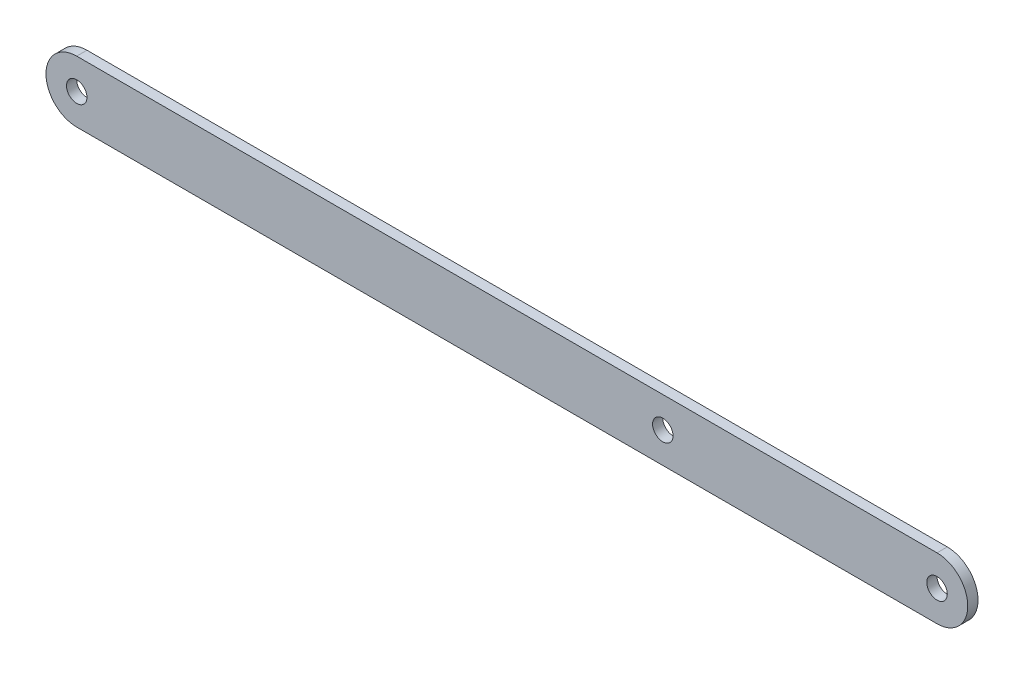
from build123d import *

# Parameters (mm, degrees)
SKETCH2_R           = 12.7
BOSS_EXTRUDE1_DEPTH = 12.7
SKETCH3_R           = 12.7
CUT_EXTRUDE1_DEPTH  = 13.7


with BuildPart() as part:
    # Sketch2 → Boss-Extrude1 (new body)
    with BuildSketch(Plane.XY):
        with BuildLine():
            Line((0, 38.1), (1066.8, 38.1))
            ThreePointArc((1066.8, 38.1), (1104.9, 0), (1066.8, -38.1))
            Line((1066.8, -38.1), (0, -38.1))
            ThreePointArc((0, -38.1), (-38.1, 0), (0, 38.1))
        make_face()
        Circle(SKETCH2_R, mode=Mode.SUBTRACT)
        with Locations((1066.8, 0)):
            Circle(SKETCH2_R, mode=Mode.SUBTRACT)
    extrude(amount=BOSS_EXTRUDE1_DEPTH)

    # Sketch3 → Cut-Extrude1 (cut, through all)
    with BuildSketch(Plane.XY.offset(12.7)):
        with Locations((726.772091625, 0)):
            Circle(SKETCH3_R)
    extrude(amount=-CUT_EXTRUDE1_DEPTH, mode=Mode.SUBTRACT)


solid = part.part
